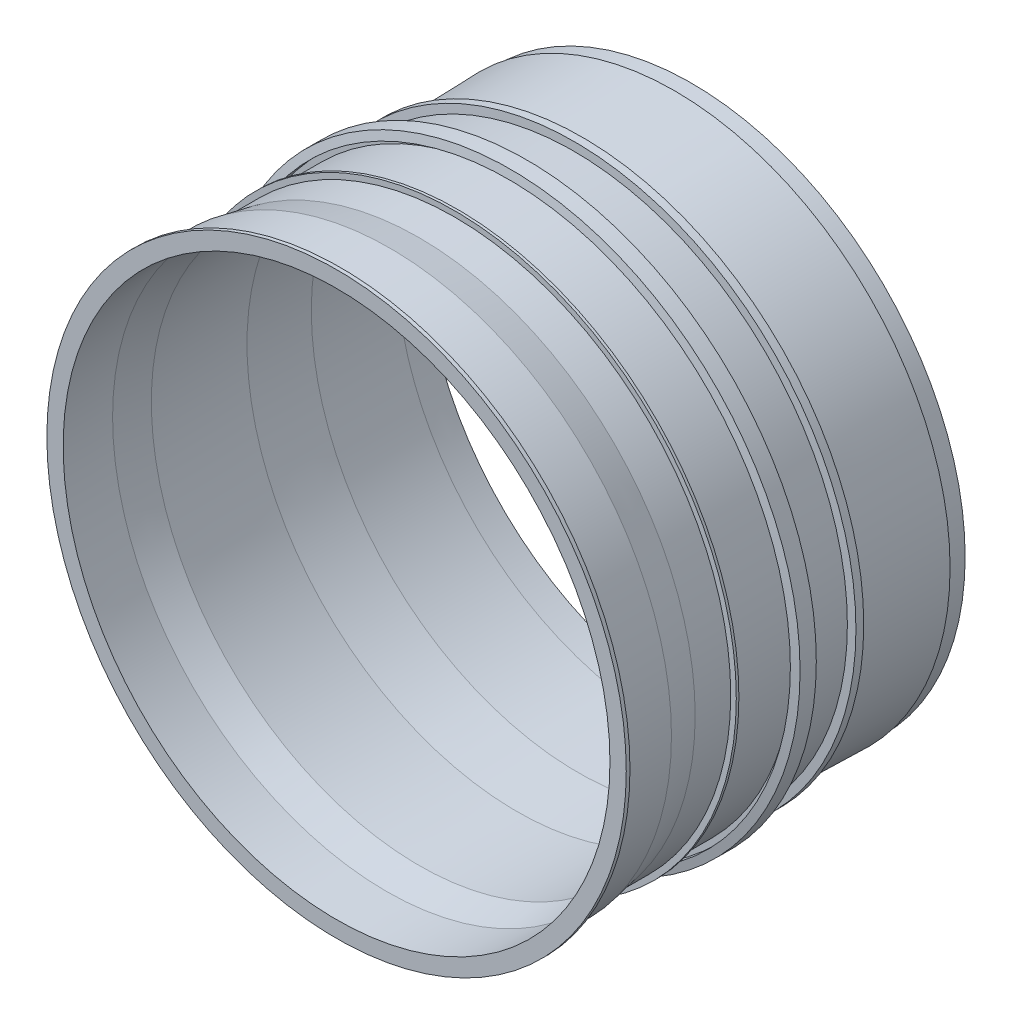
from build123d import *


with BuildPart() as part:
    # Sketch3 → Revolve1 (revolve)
    with BuildSketch(Plane(origin=(0, 0, 0), x_dir=(0, 0, -1), z_dir=(1, 0, 0))):
        Polygon((625.243112709, 1107.27781024), (625.243112709, 1173.292710159), (640.246499054, 1173.292710159), (640.246499054, 1140.2852602), (841.291876078, 1140.2852602), (959.818628204, 1117.780180682), (1103.851137117, 1117.780180682), (1103.851137117, 1140.2852602), (1114.353507559, 1140.2852602), (1114.353507559, 1117.780180682), (1355.908027715, 1117.780180682), (1355.908027715, 1140.2852602), (1322.900577755, 1140.2852602), (1329.167815089, 1173.292710159), (1394.916832212, 1173.292710159), (1412.953814648, 1140.2852602), (1373.733715244, 1140.2852602), (1373.733715244, 1117.780180682), (1586.7930511, 1107.27781024), (1588.420093001, 1140.2852602), (1619.967627388, 1140.2852602), (1619.967627388, 1123.78153522), (1619.967627388, 1107.27781024), (1994.47135604, 1115.52967273), (1994.47135604, 1107.27781024), (2063.698238778, 1107.27781024), (2063.698238778, 1083.769640902), (1949.05197346, 1081.243510602), (1903.269357476, 1081.243510602), (1604.193860195, 1081.243510602), (1355.908027715, 1093.482306793), (959.818628204, 1084.754822903), (827.962379457, 1109.790819501), align=None)
    revolve(axis=Axis((0, 0, 0), (0, 0, -1)))


solid = part.part
